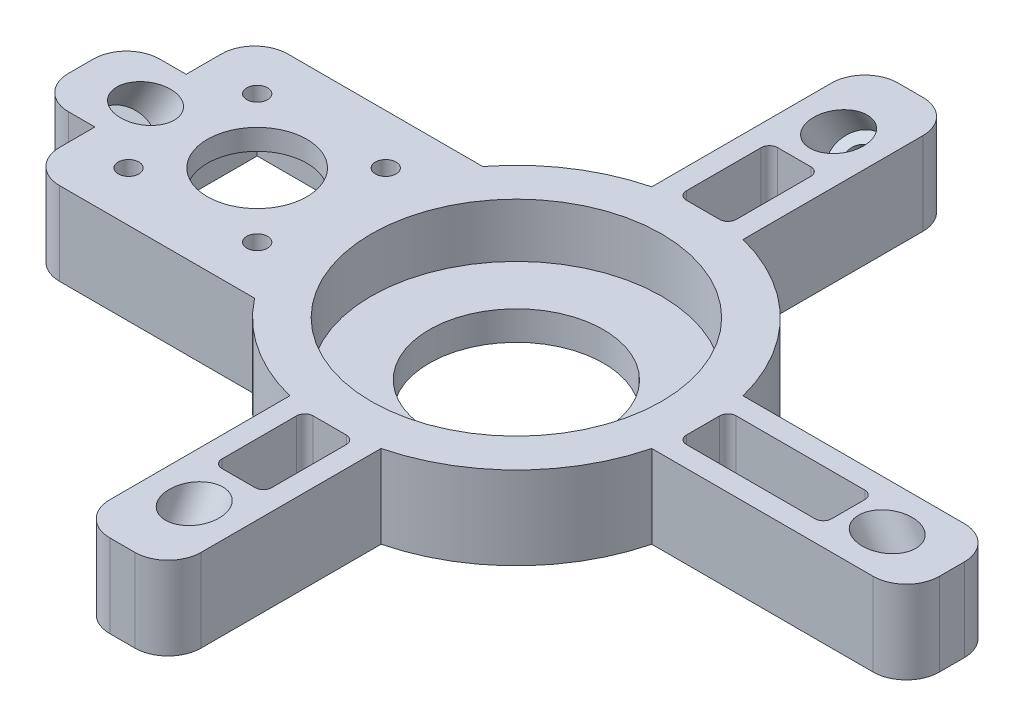
from build123d import *

# Parameters (mm, degrees)
SKETCH_1_R          = 21
EXTRUDE_1_DEPTH     = 20
EXTRUDE_2_DEPTH     = 20
SKETCH_6_R          = 35
CUT_EXTRUDE_4_DEPTH = 13
SKETCH_4_R          = 2.5
SKETCH_4_R_2        = 12
CUT_EXTRUDE_3_DEPTH = 21
SKETCH_7_W          = 45
SKETCH_7_H          = 45
CUT_EXTRUDE_5_DEPTH = 15
SKETCH_2_R          = 6
CUT_EXTRUDE_1_DEPTH = 54
SKETCH_3_R          = 3.1
CUT_EXTRUDE_2_DEPTH = 17.320508076
SKETCH_8_R          = 6
CUT_EXTRUDE_6_DEPTH = 61
SKETCH_9_R          = 3.1
CUT_EXTRUDE_7_DEPTH = 15.320508076
FILLET_1_R          = 8
SKETCH_10_W         = 12
SKETCH_10_H         = 22
SKETCH_10_W_2       = 35
SKETCH_10_H_2       = 12
CUT_EXTRUDE_8_DEPTH = 21
FILLET_2_R          = 2


with BuildPart() as part:
    # Эскиз1 → Бобышка-Вытянуть1 (new body)
    with BuildSketch(Plane(origin=(0, 0, 0), x_dir=(1, 0, 0), z_dir=(0, 1, 0))):
        with BuildLine():
            Line((-11, 43.634848459), (-11, 95))
            Line((-11, 95), (11, 95))
            Line((11, 95), (11, 43.634848459))
            ThreePointArc((11, 43.634848459), (31.819805153, 31.819805153), (43.634848459, 11))
            Line((43.634848459, 11), (105, 11))
            Line((105, 11), (105, -11))
            Line((105, -11), (43.634848459, -11))
            ThreePointArc((43.634848459, -11), (31.819805153, -31.819805153), (11, -43.634848459))
            Line((11, -43.634848459), (11, -95))
            Line((11, -95), (-11, -95))
            Line((-11, -95), (-11, -43.634848459))
            ThreePointArc((-11, -43.634848459), (-31.819805153, -31.819805153), (-43.634848459, -11))
            Line((-43.634848459, -11), (-105, -11))
            Line((-105, -11), (-105, 11))
            Line((-105, 11), (-43.634848459, 11))
            ThreePointArc((-43.634848459, 11), (-31.819805153, 31.819805153), (-11, 43.634848459))
        make_face()
        Circle(SKETCH_1_R, mode=Mode.SUBTRACT)
    extrude(amount=EXTRUDE_1_DEPTH)

    # Эскиз5 → Бобышка-Вытянуть2 (add, through all)
    with BuildSketch(Plane(origin=(0, 20, 0), x_dir=(1, 0, 0), z_dir=(0, 1, 0))):
        with BuildLine():
            Line((-35.619517122, 27.5), (-90.619517122, 27.5))
            Line((-90.619517122, 27.5), (-90.619517122, 11))
            Line((-90.619517122, 11), (-43.634848459, 11))
            ThreePointArc((-43.634848459, 11), (-40.476859017, 19.662753726), (-35.619517122, 27.5))
        make_face()
        with BuildLine():
            Line((-35.619517122, -27.5), (-90.619517122, -27.5))
            Line((-90.619517122, -27.5), (-90.619517122, -11))
            Line((-90.619517122, -11), (-43.634848459, -11))
            ThreePointArc((-43.634848459, -11), (-40.476859017, -19.662753726), (-35.619517122, -27.5))
        make_face()
    extrude(amount=-EXTRUDE_2_DEPTH)

    # Эскиз6 → Вырез-Вытянуть4 (cut)
    with BuildSketch(Plane(origin=(0, 20, 0), x_dir=(1, 0, 0), z_dir=(0, 1, 0))):
        Circle(SKETCH_6_R)
    extrude(amount=-CUT_EXTRUDE_4_DEPTH, mode=Mode.SUBTRACT)

    # Эскиз4 → Вырез-Вытянуть3 (cut, through all)
    with BuildSketch(Plane(origin=(0, 20, 0), x_dir=(1, 0, 0), z_dir=(0, 1, 0))):
        with Locations((-47, 15.5)):
            Circle(SKETCH_4_R)
        with Locations((-78, 15.5)):
            Circle(SKETCH_4_R)
        with Locations((-78, -15.5)):
            Circle(SKETCH_4_R)
        with Locations((-47, -15.5)):
            Circle(SKETCH_4_R)
        with Locations((-62.5, 0)):
            Circle(SKETCH_4_R_2)
    extrude(amount=-CUT_EXTRUDE_3_DEPTH, mode=Mode.SUBTRACT)

    # Эскиз7 → Вырез-Вытянуть5 (cut)
    with BuildSketch(Plane.XZ):
        with Locations((-62.5, 0)):
            Rectangle(SKETCH_7_W, SKETCH_7_H)
    extrude(amount=-CUT_EXTRUDE_5_DEPTH, mode=Mode.SUBTRACT)

    # Эскиз2 → Вырез-Вытянуть1 (cut)
    with BuildSketch(Plane(origin=(0, 19.763139721, 11.410254038), x_dir=(1, 0, 0), z_dir=(0, 0.866025404, 0.5))):
        with Locations((0, 77.27241336)):
            Circle(SKETCH_2_R)
    cut_extrude_1 = extrude(amount=-CUT_EXTRUDE_1_DEPTH, mode=Mode.SUBTRACT)

    # Эскиз3 → Вырез-Вытянуть2 (cut, through all)
    with BuildSketch(Plane(origin=(0, -27.002232084, -15.589745962), x_dir=(1, 0, 0), z_dir=(0, 0.866025404, 0.5))):
        with Locations((0, 77.27241336)):
            Circle(SKETCH_3_R)
    cut_extrude_2 = extrude(amount=-CUT_EXTRUDE_2_DEPTH, mode=Mode.SUBTRACT)

    # Эскиз8 → Вырез-Вытянуть6 (cut)
    with BuildSketch(Plane(origin=(11.410254038, 19.763139721, 0), x_dir=(0, 0, -1), z_dir=(0.5, 0.866025404, 0))):
        with Locations((0, 87.432667397)):
            Circle(SKETCH_8_R)
    cut_extrude_6 = extrude(amount=-CUT_EXTRUDE_6_DEPTH, mode=Mode.SUBTRACT)

    # Эскиз9 → Вырез-Вытянуть7 (cut, through all)
    with BuildSketch(Plane(origin=(-19.089745962, -33.06440991, 0), x_dir=(0.866025404, -0.5, 0), z_dir=(0.5, 0.866025404, 0))):
        with Locations((-87.432667397, 0)):
            Circle(SKETCH_9_R)
    cut_extrude_7 = extrude(amount=-CUT_EXTRUDE_7_DEPTH, mode=Mode.SUBTRACT)

    # Скругление1
    fillet_1_edges = [part.edges().sort_by_distance(p)[0] for p in [
        (-11, 10, -95),
        (11, 10, -95),
        (105, 10, -11),
        (105, 10, 11),
        (11, 10, 95),
        (-11, 10, 95),
        (-105, 10, 11),
        (-105, 10, -11),
        (-90.619517122, 10, -27.5),
        (-90.619517122, 10, 27.5),
    ]]
    fillet(fillet_1_edges, radius=FILLET_1_R)

    # Зеркальное отражение1: Вырез-Вытянуть1, Вырез-Вытянуть2 across plane
    add(cut_extrude_1.mirror(Plane.XY), mode=Mode.SUBTRACT)
    add(cut_extrude_2.mirror(Plane.XY), mode=Mode.SUBTRACT)

    # Зеркальное отражение2: Вырез-Вытянуть6, Вырез-Вытянуть7 across plane
    add(cut_extrude_6.mirror(Plane(origin=(0, 0, 0), x_dir=(0, 0, 1), z_dir=(1, 0, 0))), mode=Mode.SUBTRACT)
    add(cut_extrude_7.mirror(Plane(origin=(0, 0, 0), x_dir=(0, 0, 1), z_dir=(1, 0, 0))), mode=Mode.SUBTRACT)

    # Эскиз10 → Вырез-Вытянуть8 (cut, through all)
    with BuildSketch(Plane(origin=(0, 20, 0), x_dir=(1, 0, 0), z_dir=(0, 1, 0))):
        with Locations((0, 56)):
            Rectangle(SKETCH_10_W, SKETCH_10_H)
        with Locations((62.5, 0)):
            Rectangle(SKETCH_10_W_2, SKETCH_10_H_2)
        with Locations((0, -56)):
            Rectangle(SKETCH_10_W, SKETCH_10_H)
    extrude(amount=-CUT_EXTRUDE_8_DEPTH, mode=Mode.SUBTRACT)

    # Скругление2
    fillet_2_edges = [part.edges().sort_by_distance(p)[0] for p in [
        (6, 10, -67),
        (6, 10, -45),
        (-6, 10, -45),
        (-6, 10, -67),
        (80, 10, -6),
        (80, 10, 6),
        (45, 10, 6),
        (45, 10, -6),
        (-6, 10, 67),
        (-6, 10, 45),
        (6, 10, 45),
        (6, 10, 67),
    ]]
    fillet(fillet_2_edges, radius=FILLET_2_R)


solid = part.part
